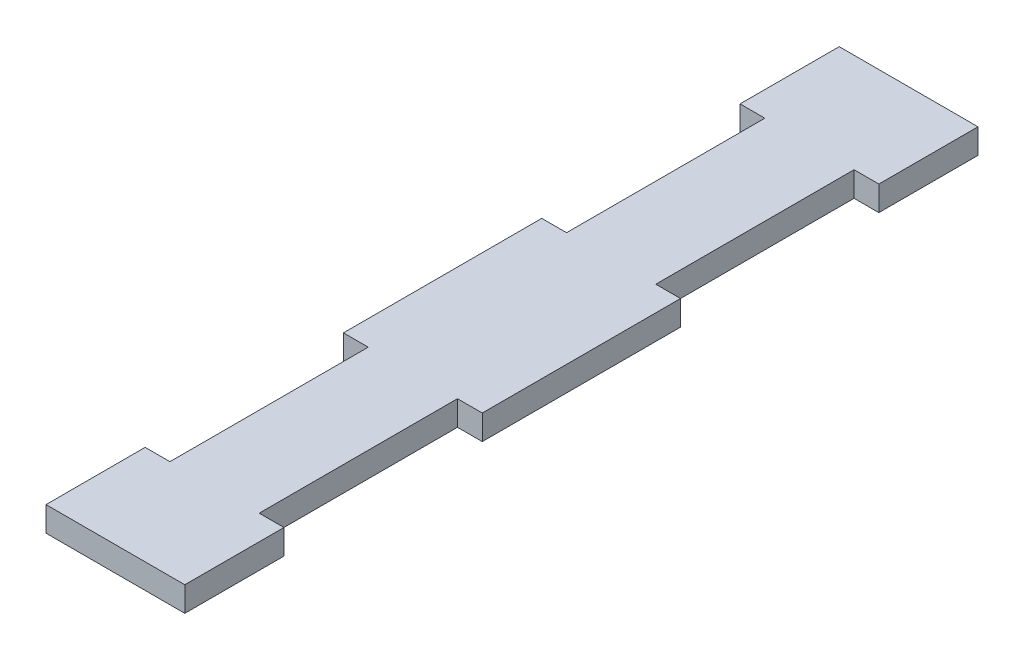
from build123d import *

# Parameters (mm, degrees)
BOSS_EXTRUDE1_DEPTH = 3.175


with BuildPart() as part:
    # Sketch1 → Boss-Extrude1 (new body)
    with BuildSketch(Plane(origin=(0, 0, 0), x_dir=(1, 0, 0), z_dir=(0, 1, 0))):
        Polygon((0, 88.9), (0, 101.6), (17.78, 101.6), (17.78, 88.9), (14.605, 88.9), (14.605, 63.5), (17.78, 63.5), (17.78, 38.1), (14.605, 38.1), (14.605, 12.7), (17.78, 12.7), (17.78, 0), (0, 0), (0, 12.7), (3.175, 12.7), (3.175, 38.1), (0, 38.1), (0, 63.5), (3.175, 63.5), (3.175, 88.9), align=None)
    extrude(amount=BOSS_EXTRUDE1_DEPTH)


solid = part.part
